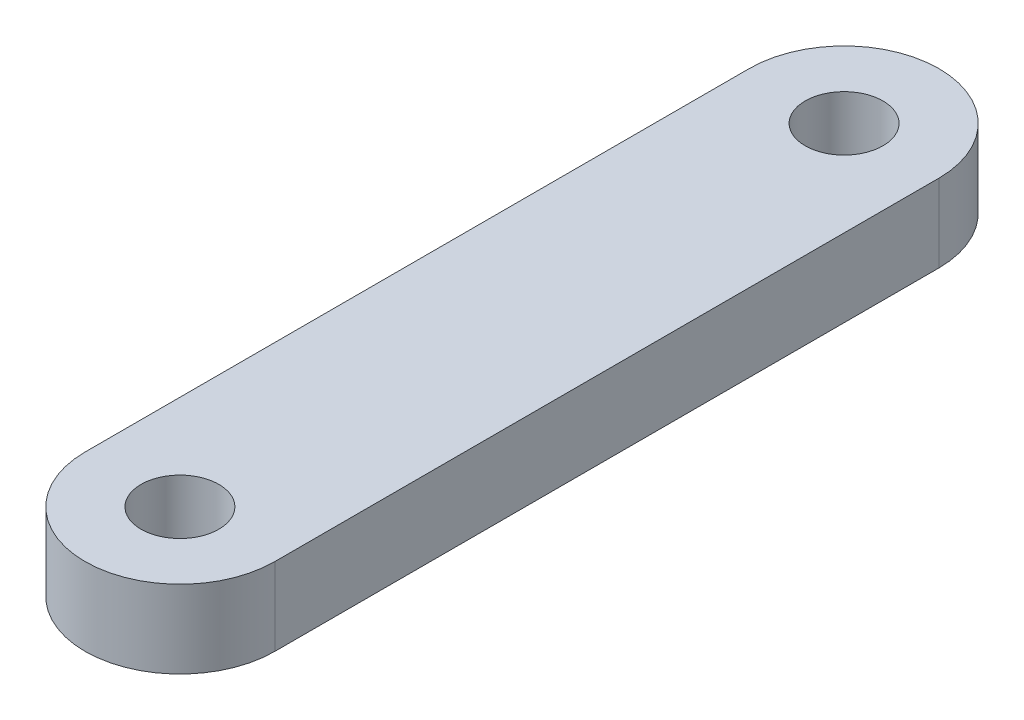
from build123d import *

# Parameters (mm, degrees)
SKETCH1_R           = 2.0828
BOSS_EXTRUDE1_DEPTH = 4.1656


with BuildPart() as part:
    # Sketch1 → Boss-Extrude1 (new body)
    with BuildSketch(Plane(origin=(0, 0, 0), x_dir=(1, 0, 0), z_dir=(0, 1, 0))):
        with BuildLine():
            Line((-5.08, 0), (-5.08, 35.56))
            ThreePointArc((-5.08, 35.56), (0, 40.64), (5.08, 35.56))
            Line((5.08, 35.56), (5.08, 0))
            ThreePointArc((5.08, 0), (0, -5.08), (-5.08, 0))
        make_face()
        with Locations((0, 35.56)):
            Circle(SKETCH1_R, mode=Mode.SUBTRACT)
        Circle(SKETCH1_R, mode=Mode.SUBTRACT)
    extrude(amount=BOSS_EXTRUDE1_DEPTH)


solid = part.part
